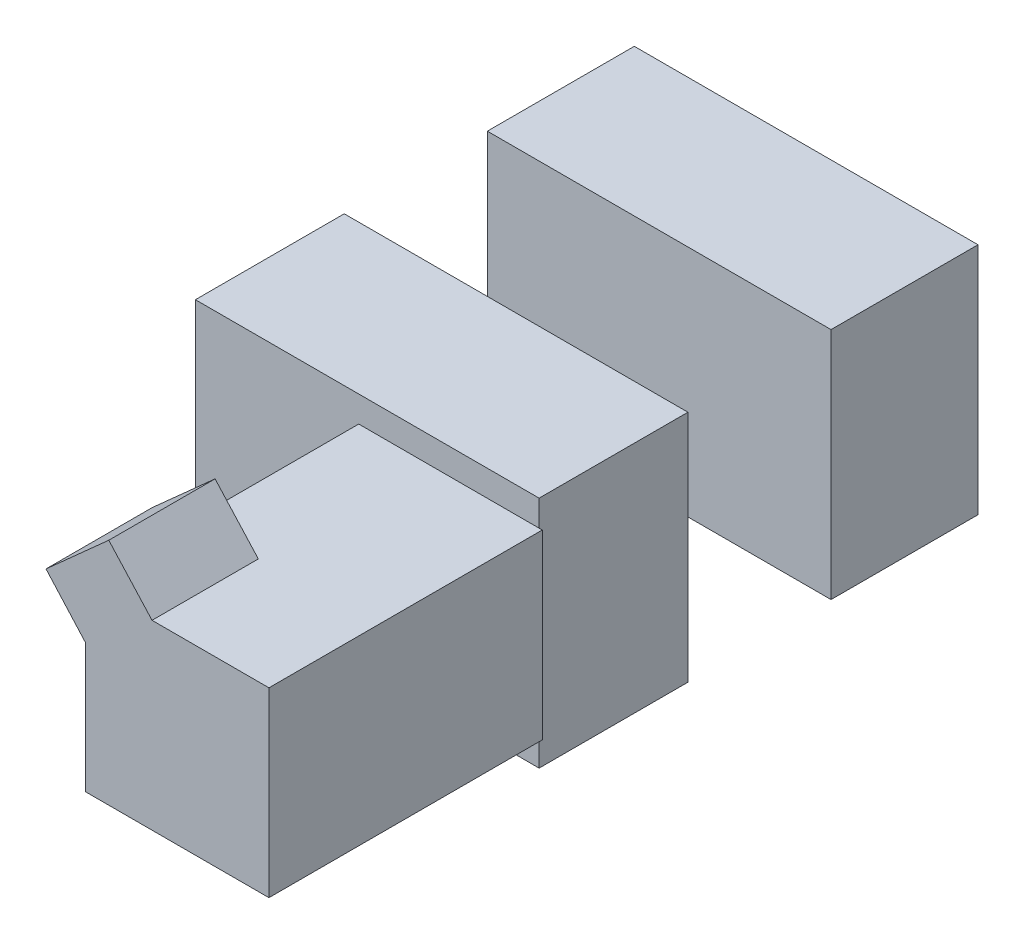
from build123d import *

# Parameters (mm, degrees)
SKETCH1_W             = 0.113177451
SKETCH1_H             = 0.048392057
BOSS_EXTRUDE1_DEPTH   = 0.0385
SKETCH1_H_2           = 0.04900298
BOSS_EXTRUDE1_2_DEPTH = 0.0385
SKETCH2_W             = 0.060435072
SKETCH2_H             = 0.059857316
BOSS_EXTRUDE2_DEPTH   = 0.09
BOSS_EXTRUDE3_DEPTH   = 0.035


with BuildPart() as part:
    # Sketch1 → Boss-Extrude1 (new body, symmetric)
    with BuildSketch(Plane(origin=(0, 0, 0), x_dir=(1, 0, 0), z_dir=(0, 1, 0))):
        with Locations((-0.027404412, 0.047911973)):
            Rectangle(SKETCH1_W, SKETCH1_H)
    extrude(amount=BOSS_EXTRUDE1_DEPTH, both=True)


with BuildPart() as body_2:
    # Sketch1 → Boss-Extrude1 2 (new body, symmetric)
    with BuildSketch(Plane(origin=(0, 0, 0), x_dir=(1, 0, 0), z_dir=(0, 1, 0))):
        with Locations((-0.027404412, -0.047911817)):
            Rectangle(SKETCH1_W, SKETCH1_H_2)
    extrude(amount=BOSS_EXTRUDE1_2_DEPTH, both=True)

    # Sketch2 → Boss-Extrude2 (add)
    with BuildSketch(Plane.XY.offset(0.072413307)):
        Rectangle(SKETCH2_W, SKETCH2_H)
    extrude(amount=BOSS_EXTRUDE2_DEPTH)

    # Sketch3 → Boss-Extrude3 (add)
    with BuildSketch(Plane.XY.offset(0.162413307)):
        Polygon((-0.030217536, 0.012636531), (-0.043195458, 0.027127409), (-0.022522092, 0.045642322), (-0.007890561, 0.029502338), align=None)
    extrude(amount=-BOSS_EXTRUDE3_DEPTH)


solid = Compound([part.part, body_2.part])
